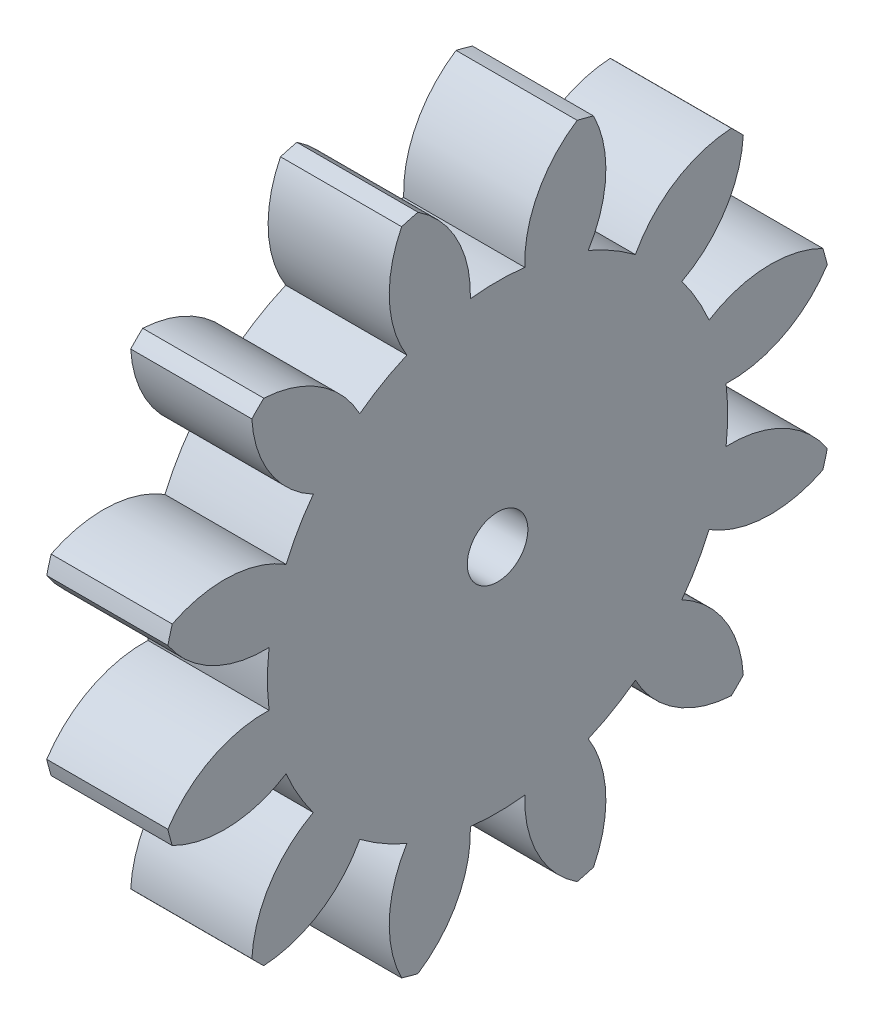
from build123d import *

# Parameters (mm, degrees)
BASPROSKE_W     = 12.7
BASPROSKE_H     = 35.56
TOOTHCUT_DEPTH  = 52.868267756
TEETHCUTS_COUNT = 12
TEETHCUTS_ANGLE = 330
BORSKE_R        = 3.175
BORE_DEPTH      = 50.8000508


with BuildPart() as part:
    # BasProSke → Base-Revolve (revolve)
    with BuildSketch(Plane(origin=(0, 0, 0), x_dir=(1, 0, 0), z_dir=(0, 1, 0)), mode=Mode.PRIVATE) as base_revolve_sk:
        with Locations((6.35, 17.78)):
            Rectangle(BASPROSKE_W, BASPROSKE_H)
    revolve(base_revolve_sk.sketch.rotate(Axis((-10, 0, 0), (1, 0, 0)), 180), axis=Axis((-10, 0, 0), (1, 0, 0)))

    # TooCutSke → ToothCut (cut, through all)
    with BuildSketch(Plane(origin=(0, 0, 0), x_dir=(0, 0, -1), z_dir=(1, 0, 0))):
        with BuildLine():
            ThreePointArc((2.852361762, 23.959541811), (0, 24.12873), (-2.852361762, 23.959541811))
            ThreePointArc((-2.852361762, 23.959541811), (-4.218005364, 29.997432638), (-8.372874517, 34.586350855))
            ThreePointArc((-8.372874517, 34.586350855), (0, 35.5854), (8.372874517, 34.586350855))
            ThreePointArc((8.372874517, 34.586350855), (4.218005364, 29.997432638), (2.852361762, 23.959541811))
        make_face()
    toothcut = extrude(amount=TOOTHCUT_DEPTH, mode=Mode.SUBTRACT)

    # TeethCuts: ToothCut ×12 about axis
    teethcuts_axis = Axis((-10, 0, 0), (1, 0, 0))
    for i in range(1, TEETHCUTS_COUNT):
        add(toothcut.rotate(teethcuts_axis, i * TEETHCUTS_ANGLE / (TEETHCUTS_COUNT - 1)), mode=Mode.SUBTRACT)

    # BorSke → Bore (cut, symmetric)
    with BuildSketch(Plane(origin=(0, 0, 0), x_dir=(0, 0, -1), z_dir=(1, 0, 0))):
        with Locations(Location((0, 0, 0), (0, 0, 180))):
            Circle(BORSKE_R)
    extrude(amount=BORE_DEPTH, both=True, mode=Mode.SUBTRACT)


solid = part.part
